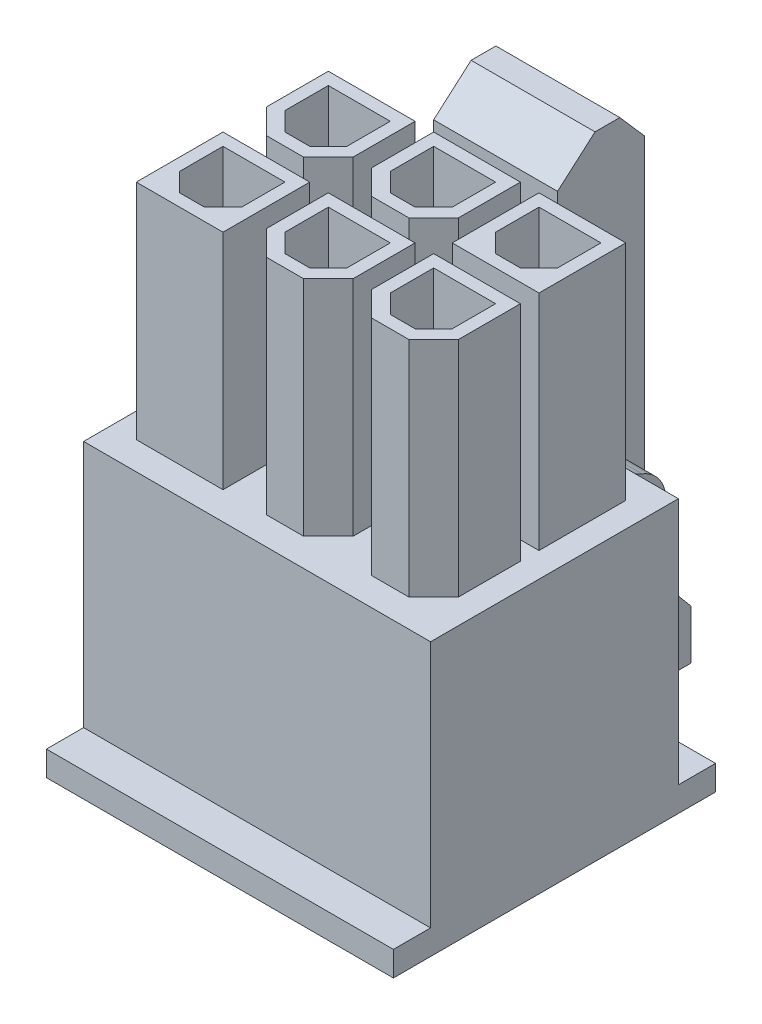
from build123d import *

# Parameters (mm, degrees)
SKIZZE1_W                       = 10
SKIZZE1_H                       = 11
AUFSATZ_LINEAR_AUSTRAGEN1_DEPTH = 7
SKIZZE2_W                       = 1.5
SKIZZE2_H                       = 1
AUFSATZ_LINEAR_AUSTRAGEN2_DEPTH = 7
AUFSATZ_LINEAR_AUSTRAGEN3_DEPTH = 4
SKIZZE4_W                       = 5
SKIZZE4_H                       = 1.5
SCHNITT_LINEAR_AUSTRAGEN1_DEPTH = 12
AUFSATZ_LINEAR_AUSTRAGEN4_DEPTH = 2.5
SKIZZE6_W                       = 3.75
SKIZZE6_H                       = 3.75
SCHNITT_LINEAR_AUSTRAGEN2_DEPTH = 10
LINEARES_MUSTER1_COUNT          = 3
LINEARES_MUSTER1_PITCH          = 4.25
LINEARES_MUSTER1_COUNT_DIR2     = 2
LINEARES_MUSTER1_PITCH_DIR2     = 4.25
SKIZZE7_W                       = 3.5
SKIZZE7_H                       = 3.5
AUFSATZ_LINEAR_AUSTRAGEN5_DEPTH = 9
LINEARES_MUSTER2_COUNT          = 3
LINEARES_MUSTER2_PITCH          = 4.25
LINEARES_MUSTER2_COUNT_DIR2     = 2
LINEARES_MUSTER2_PITCH_DIR2     = 4.25
AUFSATZ_LINEAR_AUSTRAGEN7_DEPTH = 9
LINEARES_MUSTER4_COUNT          = 3
LINEARES_MUSTER4_PITCH          = 4.25
LINEARES_MUSTER4_COUNT_DIR2     = 2
LINEARES_MUSTER4_PITCH_DIR2     = 4.25
SCHNITT_LINEAR_AUSTRAGEN4_DEPTH = 21
LINEARES_MUSTER6_COUNT          = 3
LINEARES_MUSTER6_PITCH          = 4.25
LINEARES_MUSTER6_COUNT_DIR2     = 2
LINEARES_MUSTER6_PITCH_DIR2     = 4.25


with BuildPart() as part:
    # Skizze1 → Aufsatz-Linear austragen1 (new body, symmetric)
    with BuildSketch(Plane(origin=(0, 0, 0), x_dir=(0, 0, -1), z_dir=(1, 0, 0))):
        with Locations((0, 5.5)):
            Rectangle(SKIZZE1_W, SKIZZE1_H)
    extrude(amount=AUFSATZ_LINEAR_AUSTRAGEN1_DEPTH, both=True)

    # Skizze2 → Aufsatz-Linear austragen2 (add, symmetric)
    with BuildSketch(Plane(origin=(0, 0, 0), x_dir=(0, 0, -1), z_dir=(1, 0, 0))):
        with Locations((-5.75, 0.5)):
            Rectangle(SKIZZE2_W, SKIZZE2_H)
        with Locations((5.75, 0.5)):
            Rectangle(SKIZZE2_W, SKIZZE2_H)
    extrude(amount=AUFSATZ_LINEAR_AUSTRAGEN2_DEPTH, both=True)

    # Skizze3 → Aufsatz-Linear austragen3 (add, symmetric)
    with BuildSketch(Plane(origin=(0, 0, 0), x_dir=(0, 0, -1), z_dir=(1, 0, 0))):
        with BuildLine():
            Line((5, 11), (5.571713615, 11))
            ThreePointArc((5.571713615, 11), (5.836038655, 10.149642784), (6.535856807, 9.598979842))
            ThreePointArc((6.535856807, 9.598979842), (7.23567496, 9.048316901), (7.5, 8.197959685))
            Line((7.5, 8.197959685), (7.5, 5.197959685))
            Line((7.5, 5.197959685), (8.5, 4))
            Line((8.5, 4), (8.5, 2))
            Line((8.5, 2), (6.5, 2))
            Line((6.5, 2), (6.5, 8))
            Line((6.5, 8), (5, 8))
            Line((5, 8), (5, 11))
        make_face()
    extrude(amount=AUFSATZ_LINEAR_AUSTRAGEN3_DEPTH, both=True)

    # Skizze4 → Schnitt-Linear austragen1 (cut, through all)
    with BuildSketch(Plane.XZ):
        with Locations((0, -5.75)):
            Rectangle(SKIZZE4_W, SKIZZE4_H)
    extrude(amount=-SCHNITT_LINEAR_AUSTRAGEN1_DEPTH, mode=Mode.SUBTRACT)

    # Skizze5 → Aufsatz-Linear austragen4 (add, symmetric)
    with BuildSketch(Plane(origin=(0, 0, 0), x_dir=(0, 0, -1), z_dir=(1, 0, 0))):
        Polygon((8.123516438, 4.451012129), (8.123516438, 19.870653012), (7.136310593, 21), (6.136310593, 21), (4.623516438, 19.677608169), (4.623516438, 17.677608169), (6.123516438, 17.677608169), (6.5, 8), (6.5, 2), align=None)
    extrude(amount=AUFSATZ_LINEAR_AUSTRAGEN4_DEPTH, both=True)

    # Skizze6 → Schnitt-Linear austragen2 (cut)
    with BuildSketch(Plane.XZ):
        with Locations((-4.25, -2.125)):
            Rectangle(SKIZZE6_W, SKIZZE6_H)
    schnitt_linear_austragen2 = extrude(amount=-SCHNITT_LINEAR_AUSTRAGEN2_DEPTH, mode=Mode.SUBTRACT)

    # Lineares Muster1: Schnitt-Linear austragen2 3 × 2
    with Locations(*[(i * LINEARES_MUSTER1_PITCH, 0, j * LINEARES_MUSTER1_PITCH_DIR2) for i in range(LINEARES_MUSTER1_COUNT) for j in range(LINEARES_MUSTER1_COUNT_DIR2) if (i, j) != (0, 0)]):
        add(schnitt_linear_austragen2, mode=Mode.SUBTRACT)

    # Skizze7 → Aufsatz-Linear austragen5 (add)
    with BuildSketch(Plane(origin=(0, 11, 0), x_dir=(1, 0, 0), z_dir=(0, 1, 0))):
        with Locations((-4.25, -2.125)):
            Rectangle(SKIZZE7_W, SKIZZE7_H)
    aufsatz_linear_austragen5 = extrude(amount=AUFSATZ_LINEAR_AUSTRAGEN5_DEPTH)

    # Lineares Muster2: Aufsatz-Linear austragen5 3 × 2, 4 skipped
    with Locations(*[(i * LINEARES_MUSTER2_PITCH, 0, -j * LINEARES_MUSTER2_PITCH_DIR2) for i in range(LINEARES_MUSTER2_COUNT) for j in range(LINEARES_MUSTER2_COUNT_DIR2) if (i, j) not in ((0, 0), (0, 1), (1, 0), (1, 1), (2, 0))]):
        add(aufsatz_linear_austragen5)

    # Skizze10 → Aufsatz-Linear austragen7 (add)
    with BuildSketch(Plane(origin=(0, 11, 0), x_dir=(1, 0, 0), z_dir=(0, 1, 0))):
        Polygon((-2.5, 1.375), (-3.5, 0.375), (-5, 0.375), (-6, 1.375), (-6, 3.875), (-2.5, 3.875), align=None)
    aufsatz_linear_austragen7 = extrude(amount=AUFSATZ_LINEAR_AUSTRAGEN7_DEPTH)

    # Lineares Muster4: Aufsatz-Linear austragen7 3 × 2, 2 skipped
    with Locations(*[(i * LINEARES_MUSTER4_PITCH, 0, j * LINEARES_MUSTER4_PITCH_DIR2) for i in range(LINEARES_MUSTER4_COUNT) for j in range(LINEARES_MUSTER4_COUNT_DIR2) if (i, j) not in ((0, 0), (0, 1), (2, 0))]):
        add(aufsatz_linear_austragen7)

    # Skizze12 → Schnitt-Linear austragen4 (cut, through all)
    with BuildSketch(Plane(origin=(0, 20, 0), x_dir=(1, 0, 0), z_dir=(0, 1, 0))):
        Polygon((-3.75, 0.875), (-3, 1.625), (-3, 3.375), (-5.5, 3.375), (-5.5, 1.625), (-4.75, 0.875), align=None)
    schnitt_linear_austragen4 = extrude(amount=-SCHNITT_LINEAR_AUSTRAGEN4_DEPTH, mode=Mode.SUBTRACT)

    # Lineares Muster6: Schnitt-Linear austragen4 3 × 2
    with Locations(*[(i * LINEARES_MUSTER6_PITCH, 0, j * LINEARES_MUSTER6_PITCH_DIR2) for i in range(LINEARES_MUSTER6_COUNT) for j in range(LINEARES_MUSTER6_COUNT_DIR2) if (i, j) != (0, 0)]):
        add(schnitt_linear_austragen4, mode=Mode.SUBTRACT)


solid = part.part
